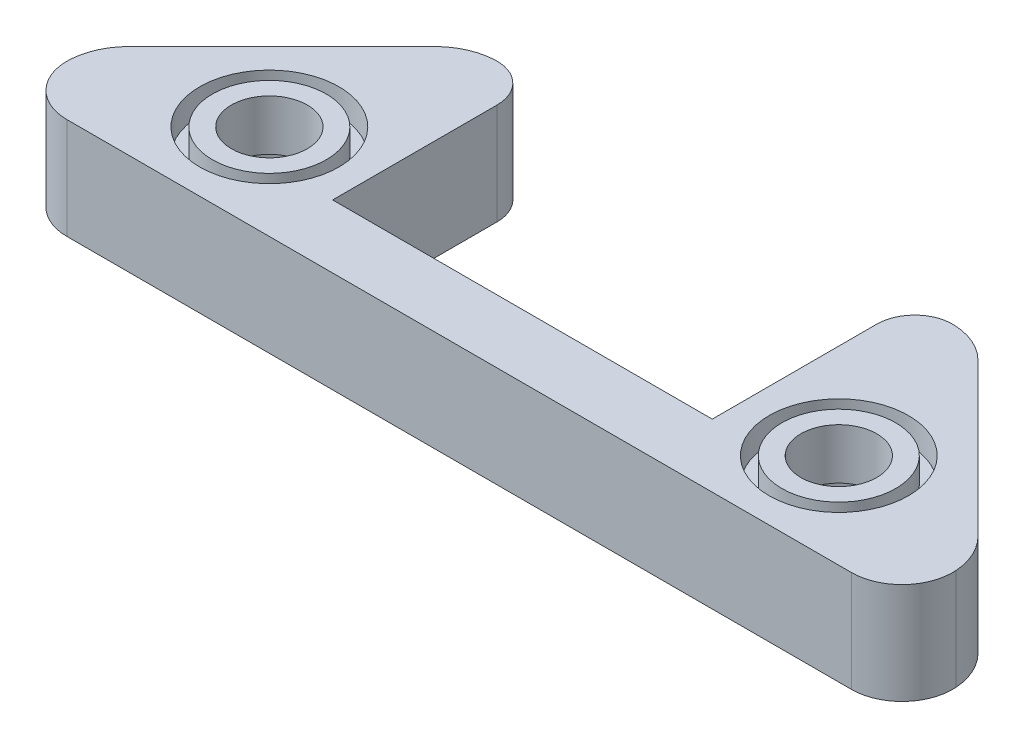
from build123d import *

# Parameters (mm, degrees)
ESQUISSE1_R             = 3
BOSS_EXTRU_1_DEPTH      = 8
ESQUISSE3_R             = 5.5
ESQUISSE3_R_2           = 4.5
ENL_V_MAT_EXTRU_2_DEPTH = 2
ESQUISSE4_R             = 6.1
ENL_V_MAT_EXTRU_3_DEPTH = 4
CONG_1_R                = 5
CONG_2_R                = 3
CONG_3_R                = 4


with BuildPart() as part:
    # Esquisse1 → Boss.-Extru.1 (new body)
    with BuildSketch(Plane(origin=(0, 0, 0), x_dir=(1, 0, 0), z_dir=(0, 1, 0))):
        Polygon((-35, 0), (35, 0), (35, 6), (20, 21), (15, 21), (15, 5), (-15, 5), (-15, 21), (-20, 21), (-35, 6), align=None)
        with Locations((22.5, 7.5)):
            Circle(ESQUISSE1_R, mode=Mode.SUBTRACT)
        with Locations((-22.5, 7.5)):
            Circle(ESQUISSE1_R, mode=Mode.SUBTRACT)
    extrude(amount=BOSS_EXTRU_1_DEPTH)

    # Esquisse3 → Enlèv. mat.-Extru.2 (cut)
    with BuildSketch(Plane(origin=(0, 8, 0), x_dir=(1, 0, 0), z_dir=(0, 1, 0))):
        with Locations((-22.5, 7.5)):
            Circle(ESQUISSE3_R)
        with Locations((-22.5, 7.5)):
            Circle(ESQUISSE3_R_2, mode=Mode.SUBTRACT)
        with Locations((22.5, 7.5)):
            Circle(ESQUISSE3_R)
        with Locations((22.5, 7.5)):
            Circle(ESQUISSE3_R_2, mode=Mode.SUBTRACT)
    extrude(amount=-ENL_V_MAT_EXTRU_2_DEPTH, mode=Mode.SUBTRACT)

    # Esquisse4 → Enlèv. mat.-Extru.3 (cut)
    with BuildSketch(Plane.XZ):
        with Locations((-22.5, -7.5)):
            Circle(ESQUISSE4_R)
        with Locations((22.5, -7.5)):
            Circle(ESQUISSE4_R)
    extrude(amount=-ENL_V_MAT_EXTRU_3_DEPTH, mode=Mode.SUBTRACT)

    # Congé1
    cong_1_edges = [part.edges().sort_by_distance(p)[0] for p in [
        (-35, 4, -6),
        (-20, 4, -21),
        (20, 4, -21),
        (35, 4, -6),
    ]]
    fillet(cong_1_edges, radius=CONG_1_R)

    # Congé2
    cong_2_edges = [part.edges().sort_by_distance(p)[0] for p in [
        (15, 4, -21),
        (-15, 4, -21),
    ]]
    fillet(cong_2_edges, radius=CONG_2_R)

    # Congé3
    cong_3_edges = [part.edges().sort_by_distance(p)[0] for p in [
        (35, 4, 0),
        (-35, 4, 0),
    ]]
    fillet(cong_3_edges, radius=CONG_3_R)


solid = part.part
